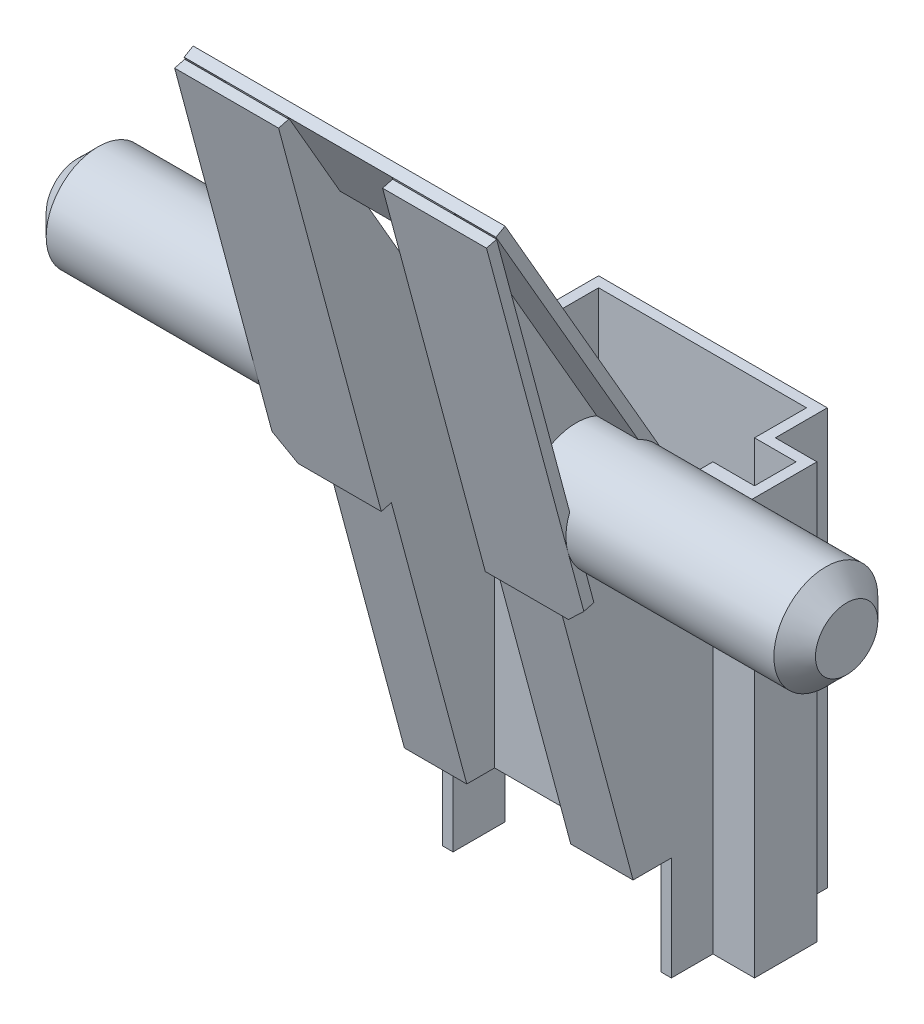
from build123d import *

# Parameters (mm, degrees)
AUFSATZ_LINEAR_AUSTRAGEN1_DEPTH = 20
AUFSATZ_LINEAR_AUSTRAGEN2_DEPTH = 15
AUFSATZ_LINEAR_AUSTRAGEN4_DEPTH = 3
SCHNITT_LINEAR_AUSTRAGEN1_REACH = 22
SKIZZE7_W                       = 10
SKIZZE7_H                       = 2
SKIZZE11_W                      = 5
SKIZZE11_H                      = 14.866025404
SCHNITT_LINEAR_AUSTRAGEN4_DEPTH = 10
SKIZZE12_W                      = 5
SKIZZE12_H                      = 19.089107003
AUFSATZ_LINEAR_AUSTRAGEN7_DEPTH = 0.5
SKIZZE13_R                      = 2.5
AUFSATZ_LINEAR_AUSTRAGEN8_DEPTH = 13
SKIZZE8_W                       = 11
SKIZZE8_H                       = 5
SCHNITT_LINEAR_AUSTRAGEN5_DEPTH = 13
FASE1_SIZE                      = 1


with BuildPart() as part:
    # Skizze1 → Aufsatz-Linear austragen1 (new body)
    with BuildSketch(Plane(origin=(0, 0, 0), x_dir=(1, 0, 0), z_dir=(0, 1, 0))):
        Polygon((5.5, -4), (-5.5, -4), (-5.5, -1.5), (-7.5, -1.5), (-7.5, 1.5), (-5.5, 1.5), (-5.5, 4), (5.5, 4), (5.5, 1.5), (7.5, 1.5), (7.5, -1.5), (5.5, -1.5), align=None)
        Polygon((-5, 1), (-5, 3.5), (5, 3.5), (5, 1), (7, 1), (7, -1), (5, -1), (5, -3.5), (-5, -3.5), (-5, -1), (-7, -1), (-7, 1), align=None, mode=Mode.SUBTRACT)
    extrude(amount=AUFSATZ_LINEAR_AUSTRAGEN1_DEPTH)

    # Skizze2 → Aufsatz-Linear austragen2 (add)
    with BuildSketch(Plane.ZY.offset(7.5)):
        Polygon((13.5, 37.320508076), (13.933012702, 37.070508076), (4, 19.866025404), (4, 19.498965661), (1.5, 19.498965661), (1.5, 20), (3.5, 20), align=None)
    extrude(amount=-AUFSATZ_LINEAR_AUSTRAGEN2_DEPTH)

    # Skizze6 → Aufsatz-Linear austragen4 (add)
    with BuildSketch(Plane.ZY.offset(5.5)):
        Polygon((13.933012702, 37.070508076), (4, 0), (4, 19.866025404), align=None)
    aufsatz_linear_austragen4 = extrude(amount=-AUFSATZ_LINEAR_AUSTRAGEN4_DEPTH)

    # Skizze7 → Schnitt-Linear austragen1 (cut, up to next)
    with BuildSketch(Plane(origin=(0, 20, 0), x_dir=(1, 0, 0), z_dir=(0, 1, 0)), mode=Mode.PRIVATE) as schnitt_linear_austragen1_sk1:
        with Locations((0, -2.5)):
            Rectangle(SKIZZE7_W, SKIZZE7_H)
    schnitt_linear_austragen1_tool1 = extrude(schnitt_linear_austragen1_sk1.sketch, amount=-SCHNITT_LINEAR_AUSTRAGEN1_REACH, mode=Mode.PRIVATE) & part.part
    add(schnitt_linear_austragen1_tool1.solids().sort_by_distance((0, 20, 2.5))[0], mode=Mode.SUBTRACT)

    # Spiegeln3: Aufsatz-Linear austragen4 across plane
    add(aufsatz_linear_austragen4.mirror(Plane(origin=(0, 0, 0), x_dir=(0, 0, 1), z_dir=(1, 0, 0))))

    # Skizze11 → Schnitt-Linear austragen4 (cut)
    with BuildSketch(Plane(origin=(0, 3.234455543, -5.602241336), x_dir=(1, 0, 0), z_dir=(0, -0.5, 0.866025404))):
        with Locations((0, 26.637495374)):
            Rectangle(SKIZZE11_W, SKIZZE11_H)
    extrude(amount=-SCHNITT_LINEAR_AUSTRAGEN4_DEPTH, mode=Mode.SUBTRACT)

    # Skizze12 → Aufsatz-Linear austragen7 (add)
    with BuildSketch(Plane(origin=(0, -1, 3.732050808), x_dir=(1, 0, 0), z_dir=(0, -0.258819045, 0.965925826))):
        with Locations((-5, 29.768936686)):
            Rectangle(SKIZZE12_W, SKIZZE12_H)
    aufsatz_linear_austragen7 = extrude(amount=AUFSATZ_LINEAR_AUSTRAGEN7_DEPTH)

    # Spiegeln4: Aufsatz-Linear austragen7 across plane
    add(aufsatz_linear_austragen7.mirror(Plane(origin=(0, 0, 0), x_dir=(0, 0, 1), z_dir=(1, 0, 0))))

    # Skizze13 → Aufsatz-Linear austragen8 (add)
    with BuildSketch(Plane(origin=(5.5, 0, 0), x_dir=(0, 0, -1), z_dir=(1, 0, 0))):
        with Locations((-8.069309397, 22.914276031)):
            Circle(SKIZZE13_R)
    aufsatz_linear_austragen8 = extrude(amount=AUFSATZ_LINEAR_AUSTRAGEN8_DEPTH)

    # Skizze8 → Schnitt-Linear austragen5 (cut)
    with BuildSketch(Plane(origin=(0, 0, 3.5), x_dir=(-1, 0, 0), z_dir=(0, 0, -1))):
        with Locations((0, 2.5)):
            Rectangle(SKIZZE8_W, SKIZZE8_H)
    extrude(amount=-SCHNITT_LINEAR_AUSTRAGEN5_DEPTH, mode=Mode.SUBTRACT)

    # Spiegeln5: Aufsatz-Linear austragen8 across plane
    add(aufsatz_linear_austragen8.mirror(Plane(origin=(0, 0, 0), x_dir=(0, 0, 1), z_dir=(1, 0, 0))))

    # Fase1
    fase1_edges = [part.edges().sort_by_distance(p)[0] for p in [
        (-7.5, 18.470549277, 9.207987808),
        (7.5, 18.470549277, 9.207987808),
        (18.5, 22.914276031, 10.569309397),
        (-18.5, 22.914276031, 10.569309397),
    ]]
    chamfer(fase1_edges, length=FASE1_SIZE)


solid = part.part
